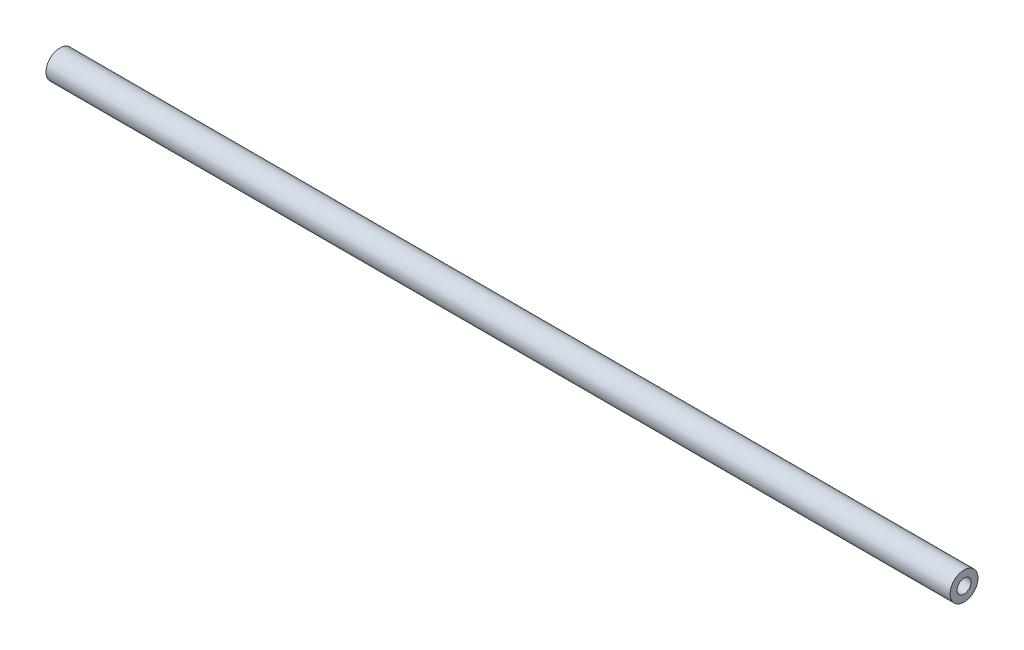
from build123d import *

# Parameters (mm, degrees)
SKETCH_1_R           = 4
SKETCH_1_R_2         = 2
EXTRUDE_1_DEPTH      = 247.54
EXTRUDE_1_DEPTH_BACK = 12


with BuildPart() as part:
    # 草图1 → 凸台-拉伸1 (new body, two sides)
    with BuildSketch(Plane(origin=(0, 0, 0), x_dir=(0, 0, -1), z_dir=(1, 0, 0))) as extrude_1_sk:
        Circle(SKETCH_1_R)
        Circle(SKETCH_1_R_2, mode=Mode.SUBTRACT)
    extrude(amount=EXTRUDE_1_DEPTH)
    extrude(extrude_1_sk.sketch, amount=-EXTRUDE_1_DEPTH_BACK)


solid = part.part
